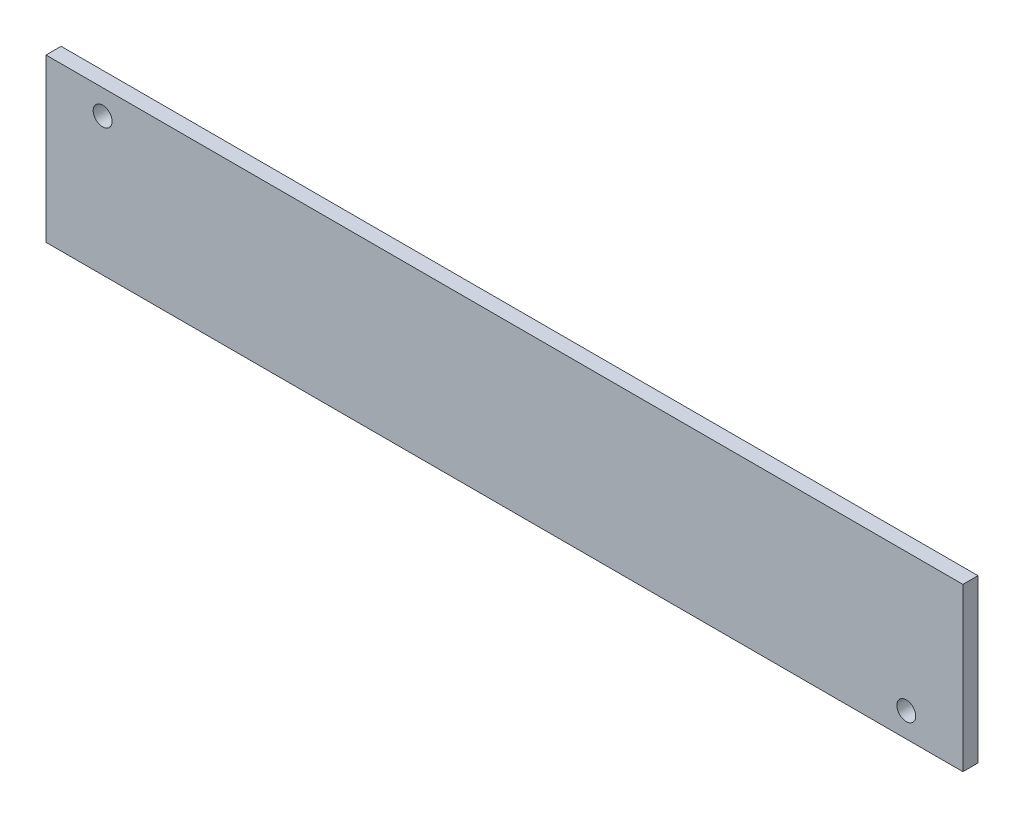
from build123d import *

# Parameters (mm, degrees)
SKETCH1_W           = 121.5
SKETCH1_H           = 21.5
BOSS_EXTRUDE1_DEPTH = 2
SKETCH2_R           = 1.25
CUT_EXTRUDE1_DEPTH  = 3


with BuildPart() as part:
    # Sketch1 → Boss-Extrude1 (new body)
    with BuildSketch(Plane.XY):
        Rectangle(SKETCH1_W, SKETCH1_H)
    extrude(amount=BOSS_EXTRUDE1_DEPTH)

    # Sketch2 → Cut-Extrude1 (cut, through all)
    with BuildSketch(Plane.XY.offset(2)):
        with Locations((-53.25, 7.5)):
            Circle(SKETCH2_R)
        with Locations((53.25, -7.5)):
            Circle(SKETCH2_R)
    extrude(amount=-CUT_EXTRUDE1_DEPTH, mode=Mode.SUBTRACT)


solid = part.part
